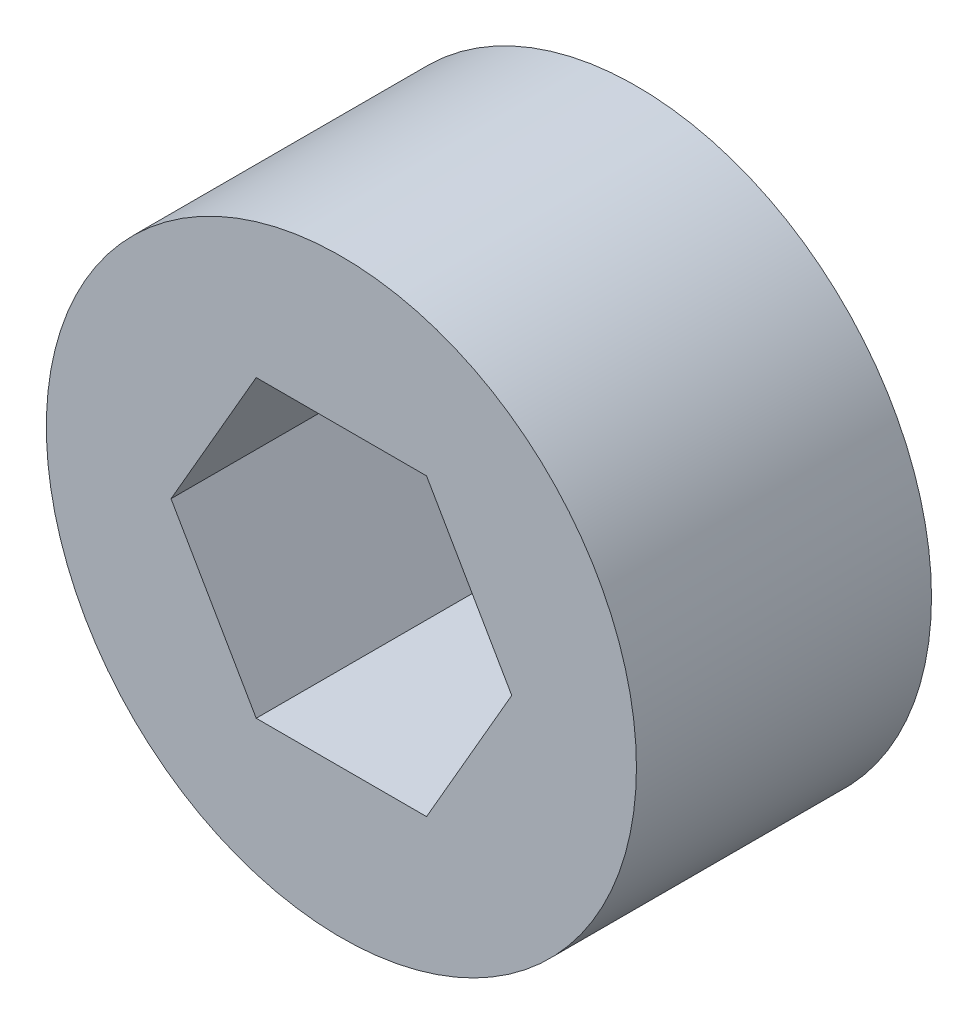
from build123d import *

# Parameters (mm, degrees)
SKETCH1_R           = 12.7
BOSS_EXTRUDE1_DEPTH = 12.7


with BuildPart() as part:
    # Sketch1 → Boss-Extrude1 (new body)
    with BuildSketch(Plane.XY):
        Circle(SKETCH1_R)
        Polygon((7.332348419, 0), (3.666174209, 6.35), (-3.666174209, 6.35), (-7.332348419, 0), (-3.666174209, -6.35), (3.666174209, -6.35), align=None, mode=Mode.SUBTRACT)
    extrude(amount=BOSS_EXTRUDE1_DEPTH)


solid = part.part
